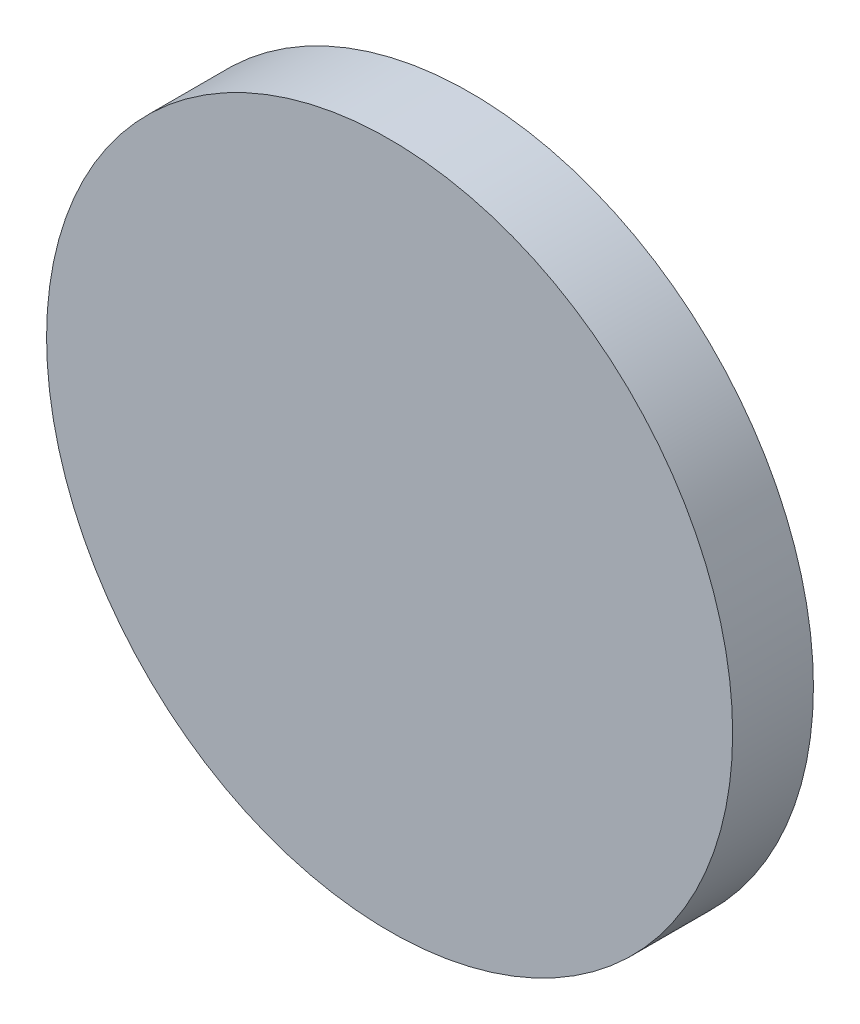
from build123d import *

# Parameters (mm, degrees)
SKETCH1_R           = 25.48
BOSS_EXTRUDE1_DEPTH = 6
SKETCH10_R          = 2
BOSS_EXTRUDE3_DEPTH = 2


with BuildPart() as part:
    # Sketch1 → Boss-Extrude1 (new body)
    with BuildSketch(Plane.XY):
        Circle(SKETCH1_R)
    extrude(amount=BOSS_EXTRUDE1_DEPTH)

    # Sketch10 → Boss-Extrude3 (add)
    with BuildSketch(Plane(origin=(0, 0, 0), x_dir=(-1, 0, 0), z_dir=(0, 0, -1))):
        with Locations((0, 13.421433997)):
            Circle(SKETCH10_R)
        with Locations((11.623302797, 6.710716999)):
            Circle(SKETCH10_R)
        with Locations((11.623302797, -6.710716999)):
            Circle(SKETCH10_R)
        with Locations((0, -13.421433997)):
            Circle(SKETCH10_R)
        with Locations((-11.623302797, -6.710716999)):
            Circle(SKETCH10_R)
        with Locations((-11.623302797, 6.710716999)):
            Circle(SKETCH10_R)
    extrude(amount=BOSS_EXTRUDE3_DEPTH)


solid = part.part
